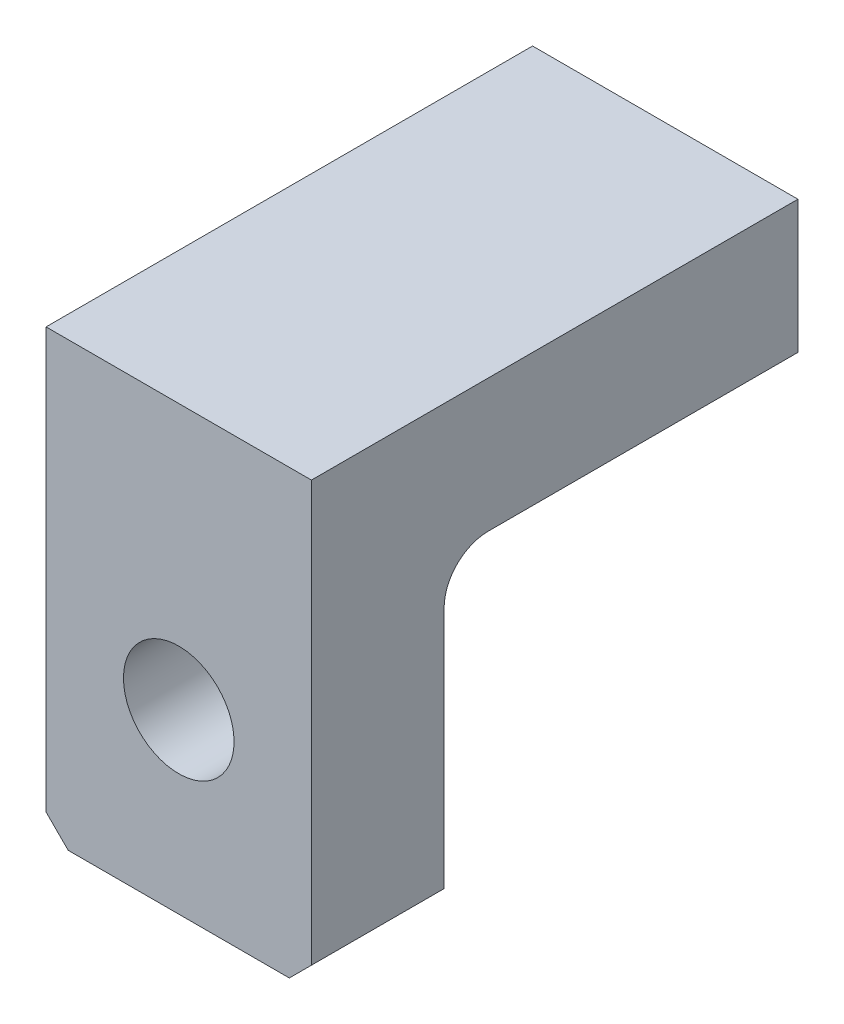
from build123d import *

# Parameters (mm, degrees)
SKICA1_W                 = 60
SKICA1_H                 = 100
P_IDAT_VYSUNUT_M1_DEPTH  = 30
SKICA2_W                 = 60
SKICA2_H                 = 30
P_IDAT_VYSUNUT_M2_DEPTH  = 80
SKICA3_R                 = 12.5
ODEBRAT_VYSUNUT_M1_DEPTH = 80
ZAOBLIT2_R               = 10
ZKOSEN_1_SIZE            = 5


with BuildPart() as part:
    # Skica1 → Přidat vysunutím1 (new body)
    with BuildSketch(Plane.XY):
        with Locations((30, 50)):
            Rectangle(SKICA1_W, SKICA1_H)
    extrude(amount=P_IDAT_VYSUNUT_M1_DEPTH)

    # Skica2 → Přidat vysunutím2 (add)
    with BuildSketch(Plane(origin=(0, 0, 0), x_dir=(-1, 0, 0), z_dir=(0, 0, -1))):
        with Locations((-30, 85)):
            Rectangle(SKICA2_W, SKICA2_H)
    extrude(amount=P_IDAT_VYSUNUT_M2_DEPTH)

    # Skica3 → Odebrat vysunutím1 (cut)
    with BuildSketch(Plane(origin=(0, 0, 0), x_dir=(-1, 0, 0), z_dir=(0, 0, -1))):
        with Locations((-30, 40)):
            Circle(SKICA3_R)
    extrude(amount=-ODEBRAT_VYSUNUT_M1_DEPTH, mode=Mode.SUBTRACT)

    # Zaoblit2
    zaoblit2_edges = [part.edges().sort_by_distance(p)[0] for p in [
        (30, 70, 0),
    ]]
    fillet(zaoblit2_edges, radius=ZAOBLIT2_R)

    # Zkosení1
    zkosen_1_edges = [part.edges().sort_by_distance(p)[0] for p in [
        (60, 0, 15),
        (0, 0, 15),
    ]]
    chamfer(zkosen_1_edges, length=ZKOSEN_1_SIZE)


solid = part.part
